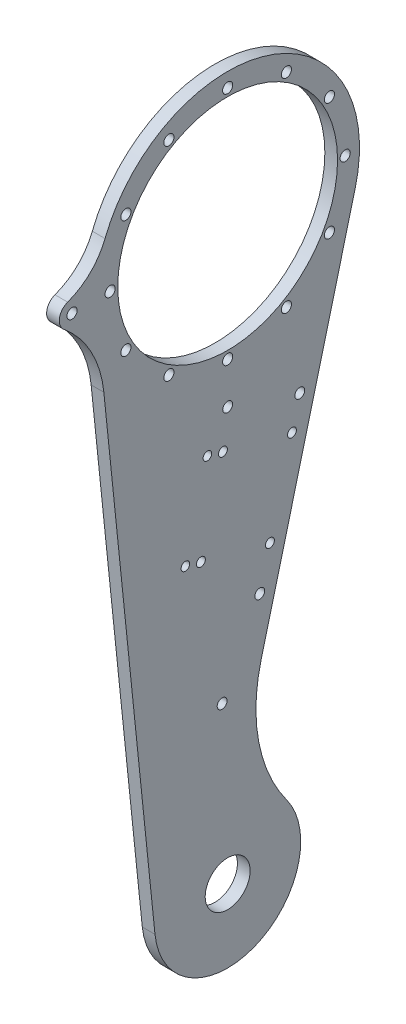
from build123d import *

# Parameters (mm, degrees)
SKETCH_1_R               = 41.5
SKETCH_1_R_2             = 23
EXTRUDE_1_DEPTH          = 4
SKETCH_3_R               = 34.6
SKETCH_3_R_2             = 7.075
CUT_EXTRUDE_2_DEPTH      = 5
SKETCH_2_R               = 1.6
CUT_EXTRUDE_1_DEPTH      = 5
PATTERN_CIRCULAR_1_COUNT = 12
FILLET_1_R               = 50
SKETCH_4_R               = 1.55
CUT_EXTRUDE_3_DEPTH      = 10
SKETCH_5_R               = 1.6
EXTRUDE_2_DEPTH          = 4
FILLET_2_R               = 20
SKETCH_6_R               = 1.55
CUT_EXTRUDE_4_DEPTH      = 10
FILLET_3_R               = 35
SKETCH_7_R               = 1.4
CUT_EXTRUDE_5_DEPTH      = 10
SKETCH_8_R               = 1.35
CUT_EXTRUDE_6_DEPTH      = 10


with BuildPart() as part:
    # 草图1 → 凸台-拉伸1 (new body)
    with BuildSketch(Plane(origin=(0, 0, 0), x_dir=(0, 0, -1), z_dir=(1, 0, 0))):
        Circle(SKETCH_1_R)
        with BuildLine():
            Line((1.96511799, -157.084103524), (40.159775356, -10.461474243))
            ThreePointArc((40.159775356, -10.461474243), (-3.1483436, -41.380405177), (-41.280230201, -4.265277778))
            Line((-41.280230201, -4.265277778), (-22.878199871, -182.363888889))
            ThreePointArc((-22.878199871, -182.363888889), (-16.404454744, -163.87877596), (1.96511799, -157.084103524))
        make_face()
        with Locations((0, -180)):
            Circle(SKETCH_1_R_2)
    extrude(amount=EXTRUDE_1_DEPTH)

    # 草图3 → 切除-拉伸2 (cut)
    with BuildSketch(Plane.ZY):
        Circle(SKETCH_3_R)
        with Locations((0, -180)):
            Circle(SKETCH_3_R_2)
    extrude(amount=-CUT_EXTRUDE_2_DEPTH, mode=Mode.SUBTRACT)

    # 草图2 → 切除-拉伸1 (cut)
    with BuildSketch(Plane.ZY):
        with Locations((0, 37)):
            Circle(SKETCH_2_R)
    cut_extrude_1 = extrude(amount=-CUT_EXTRUDE_1_DEPTH, mode=Mode.SUBTRACT)

    # 阵列(圆周)1: 切除-拉伸1 ×12 about axis
    pattern_circular_1_axis = Axis((0, 0, 0), (1, 0, 0))
    for i in range(1, PATTERN_CIRCULAR_1_COUNT):
        add(cut_extrude_1.rotate(pattern_circular_1_axis, i * 360 / PATTERN_CIRCULAR_1_COUNT), mode=Mode.SUBTRACT)

    # 圆角1
    fillet_1_edges = [part.edges().sort_by_distance(p)[0] for p in [
        (2, -157.084103524, -1.96511799),
    ]]
    fillet(fillet_1_edges, radius=FILLET_1_R)

    # 草图4 → 切除-拉伸3 (cut)
    with BuildSketch(Plane(origin=(4, 0, 0), x_dir=(0, 0, -1), z_dir=(1, 0, 0))):
        with Locations((22.71706237, -57.586327173)):
            Circle(SKETCH_4_R)
        with Locations((10.112876536, -105.971598687)):
            Circle(SKETCH_4_R)
    extrude(amount=-CUT_EXTRUDE_3_DEPTH, mode=Mode.SUBTRACT)

    # 草图5 → 凸台-拉伸2 (add)
    with BuildSketch(Plane(origin=(4, 0, 0), x_dir=(0, 0, -1), z_dir=(1, 0, 0))):
        with BuildLine():
            Line((-41.306779105, 4), (-49, 4))
            ThreePointArc((-49, 4), (-53, 0), (-49, -4))
            Line((-49, -4), (-41.306779105, -4))
            ThreePointArc((-41.306779105, -4), (-41.5, 0), (-41.306779105, 4))
        make_face()
        with Locations((-49, 0)):
            Circle(SKETCH_5_R, mode=Mode.SUBTRACT)
    extrude(amount=-EXTRUDE_2_DEPTH)

    # 圆角2
    fillet_2_edges = [part.edges().sort_by_distance(p)[0] for p in [
        (2, 4, 41.306779105),
    ]]
    fillet(fillet_2_edges, radius=FILLET_2_R)

    # 草图6 → 切除-拉伸4 (cut)
    with BuildSketch(Plane(origin=(4, 0, 0), x_dir=(0, 0, -1), z_dir=(1, 0, 0))):
        with Locations((0, -50)):
            Circle(SKETCH_6_R)
        with Locations((-1.746038475, -130)):
            Circle(SKETCH_6_R)
    extrude(amount=-CUT_EXTRUDE_4_DEPTH, mode=Mode.SUBTRACT)

    # 圆角3
    fillet_3_edges = [part.edges().sort_by_distance(p)[0] for p in [
        (2, -4, 41.306779105),
    ]]
    fillet(fillet_3_edges, radius=FILLET_3_R)

    # 草图7 → 切除-拉伸5 (cut)
    with BuildSketch(Plane(origin=(4, 0, 0), x_dir=(0, 0, -1), z_dir=(1, 0, 0))):
        with Locations((-1.493538323, -61.450142252)):
            Circle(SKETCH_7_R)
        with Locations((20.236020893, -67.110612761)):
            Circle(SKETCH_7_R)
        with Locations((-8.425840532, -88.062041585)):
            Circle(SKETCH_7_R)
        with Locations((13.303718684, -93.722512094)):
            Circle(SKETCH_7_R)
    extrude(amount=-CUT_EXTRUDE_5_DEPTH, mode=Mode.SUBTRACT)

    # 草图8 → 切除-拉伸6 (cut)
    with BuildSketch(Plane(origin=(4, 0, 0), x_dir=(0, 0, -1), z_dir=(1, 0, 0))):
        with Locations((-6.375878439, -60.178310552)):
            Circle(SKETCH_8_R)
        with Locations((-13.308180648, -86.790209885)):
            Circle(SKETCH_8_R)
    extrude(amount=-CUT_EXTRUDE_6_DEPTH, mode=Mode.SUBTRACT)


solid = part.part
